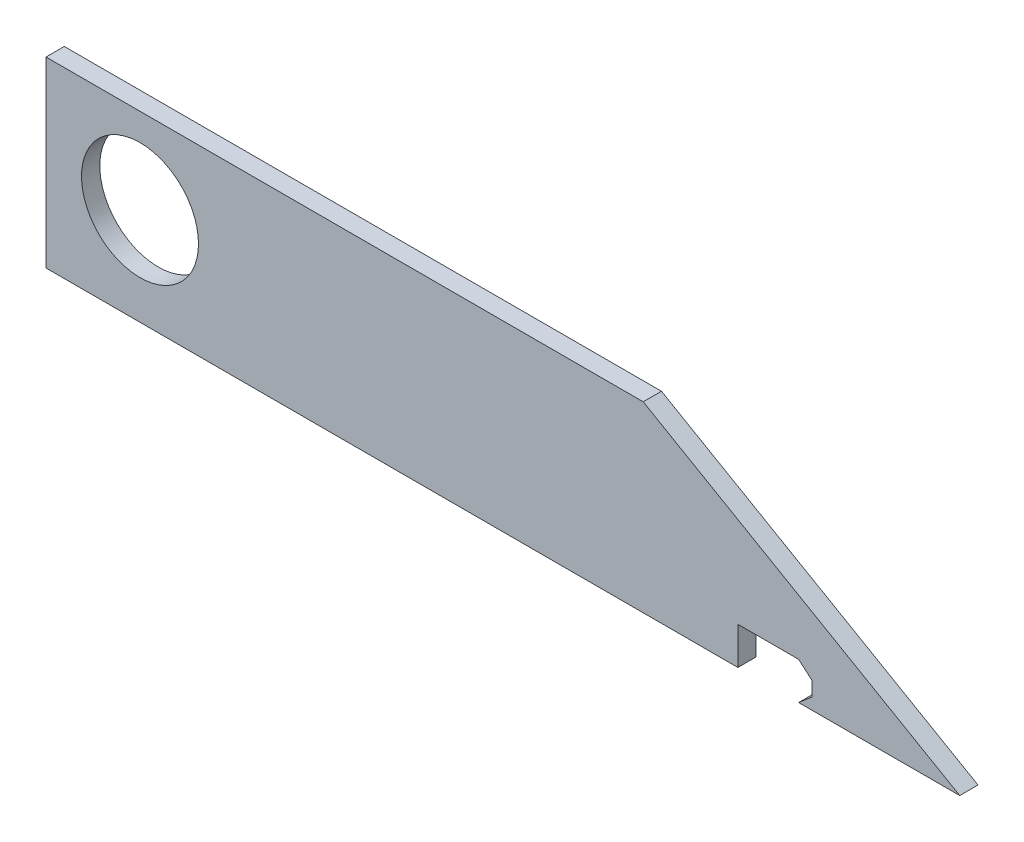
from build123d import *

# Parameters (mm, degrees)
BOSS_EXTRUDE1_DEPTH = 2.54
SKETCH3_R           = 8.128
CUT_EXTRUDE1_DEPTH  = 2.54
CUT_EXTRUDE2_DEPTH  = 3.54


with BuildPart() as part:
    # Sketch2 → Boss-Extrude1 (new body)
    with BuildSketch(Plane.XY):
        Polygon((-63.5, 2.4), (63.5, 2.4), (19.505909488, 27.8), (-63.5, 27.8), align=None)
    extrude(amount=-BOSS_EXTRUDE1_DEPTH)

    # Sketch3 → Cut-Extrude1 (cut)
    with BuildSketch(Plane.XY):
        with Locations((-50.434775134, 15.906072529)):
            Circle(SKETCH3_R)
    extrude(amount=-CUT_EXTRUDE1_DEPTH, mode=Mode.SUBTRACT)

    # Sketch4 → Cut-Extrude2 (cut, through all)
    with BuildSketch(Plane(origin=(0, 0, -2.54), x_dir=(-1, 0, 0), z_dir=(0, 0, -1))):
        Polygon((-41.105403431, 7.6), (-32.667342272, 7.6), (-32.667342272, 2.4), (-41.105403431, 2.4), (-42.967342272, 4), (-42.967342272, 6), align=None)
    extrude(amount=-CUT_EXTRUDE2_DEPTH, mode=Mode.SUBTRACT)


solid = part.part
